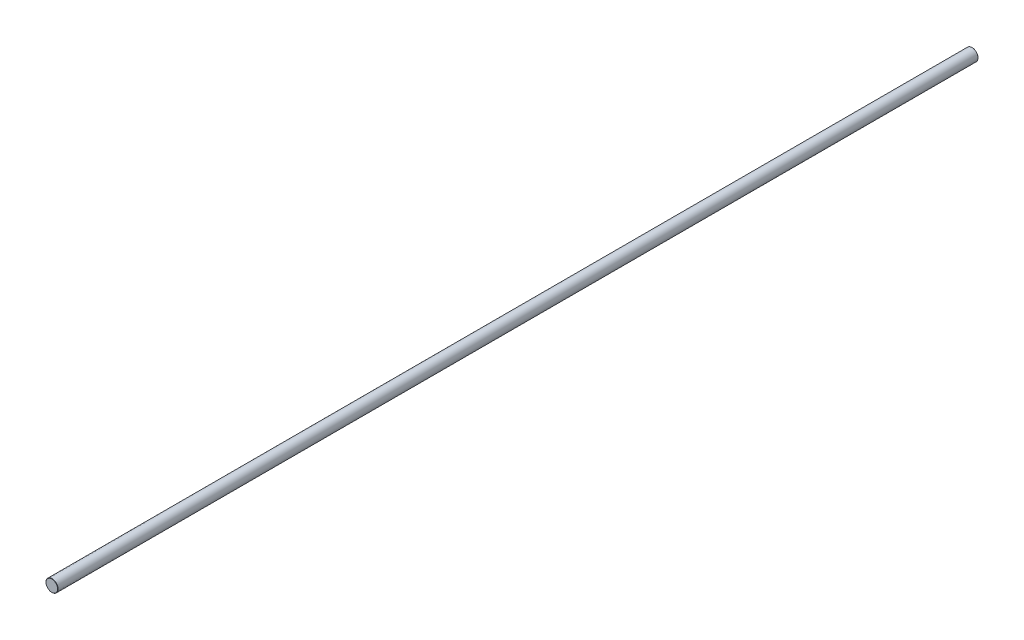
from build123d import *

# Parameters (mm, degrees)
SKETCH3_R                = 6
BOSS_EXTRUDE1_DEPTH      = 457.5
BOSS_EXTRUDE1_DEPTH_BACK = 457.5
CHAMFER1_SIZE            = 0.24


with BuildPart() as part:
    # Sketch3 → Boss-Extrude1 (new body, two sides)
    with BuildSketch(Plane.XY) as boss_extrude1_sk:
        Circle(SKETCH3_R)
    extrude(amount=BOSS_EXTRUDE1_DEPTH)
    extrude(boss_extrude1_sk.sketch, amount=-BOSS_EXTRUDE1_DEPTH_BACK)

    # Chamfer1
    chamfer1_edges = [part.edges().sort_by_distance(p)[0] for p in [
        (-6, 0, -457.5),
        (-6, 0, 457.5),
    ]]
    chamfer(chamfer1_edges, length=CHAMFER1_SIZE)


solid = part.part
